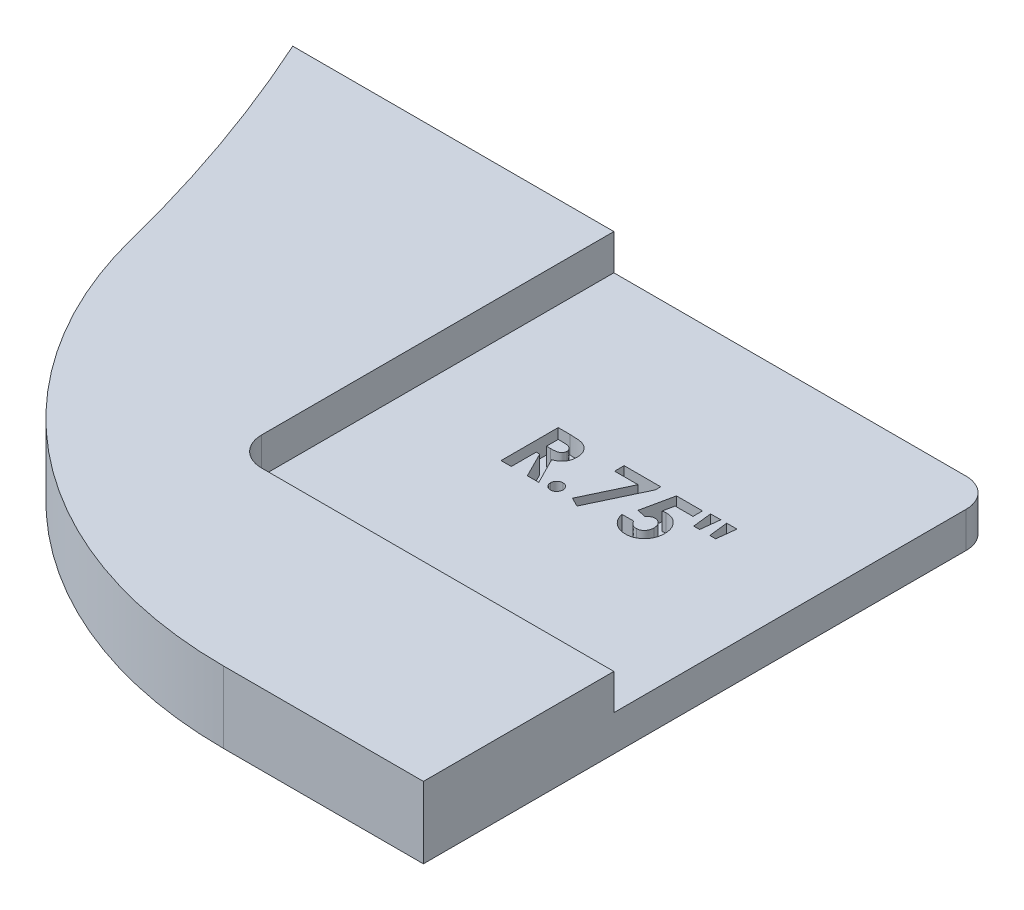
from build123d import *

# Parameters (mm, degrees)
BOSS_EXTRUDE1_DEPTH = 1.5875
FILLET1_R           = 19.05
SKETCH3_W           = 16.933333333
SKETCH3_H           = 16.933333333
CUT_EXTRUDE1_DEPTH  = 1.5875
CUT_EXTRUDE2_DEPTH  = 0.79375
FILLET2_R           = 1.27


with BuildPart() as part:
    # Sketch2 → Boss-Extrude1 (new, symmetric)
    with BuildSketch(Plane(origin=(0, 0, 0), x_dir=(1, 0, 0), z_dir=(0, 1, 0))):
        with BuildLine():
            Line((65.385731385, 1.5875), (90.785731385, 1.5875))
            Line((90.785731385, 1.5875), (90.785731385, 26.9875))
            Line((90.785731385, 26.9875), (59.577586966, 26.9875))
            ThreePointArc((59.577586966, 26.9875), (63.75929527, 14.579653345), (65.385731385, 1.5875))
        make_face()
    extrude(amount=BOSS_EXTRUDE1_DEPTH, both=True)

    # Fillet1
    fillet1_edges = [part.edges().sort_by_distance(p)[0] for p in [
        (65.385731385, 0, -1.5875),
    ]]
    fillet(fillet1_edges, radius=FILLET1_R)

    # Sketch3 → Cut-Extrude1 (cut)
    with BuildSketch(Plane(origin=(0, 1.5875, 0), x_dir=(1, 0, 0), z_dir=(0, 1, 0))):
        with Locations((82.319064719, 18.520833334)):
            Rectangle(SKETCH3_W, SKETCH3_H)
    extrude(amount=-CUT_EXTRUDE1_DEPTH, mode=Mode.SUBTRACT)

    # Sketch4 → Cut-Extrude2 (cut)
    with BuildSketch(Plane(origin=(0, 0, 0), x_dir=(1, 0, 0), z_dir=(0, 1, 0))):
        with BuildLine():
            Line((78.574192923, 19.790833333), (79.105394847, 19.790833333))
            add(Edge.make_bspline(
                [(79.105394847, 19.790833333), (79.140507132, 19.790708705), (79.208037947, 19.790469009), (79.305413695, 19.786687247), (79.39486671, 19.781424614), (79.476529437, 19.773393697), (79.550366938, 19.762745672), (79.616453216, 19.750193413), (79.67478634, 19.735887422), (79.725858268, 19.718061028), (79.771948157, 19.697953127), (79.814910342, 19.674848779), (79.855692632, 19.64900526), (79.894022441, 19.619742555), (79.930232865, 19.587587095), (79.964392216, 19.552506512), (79.996017791, 19.514203335), (80.024913764, 19.472919594), (80.051250117, 19.429490045), (80.07452593, 19.383855059), (80.093453859, 19.3359829), (80.110178714, 19.286565425), (80.122225085, 19.234896199), (80.13060316, 19.181478234), (80.136737259, 19.12612349), (80.13708994, 19.088517935), (80.137269847, 19.069334936)],
                knots=[0, 0, 0, 0, 1.749336639, 3.364467119, 4.854658419, 6.213483162, 7.451590619, 8.570285859, 9.5643256, 10.440900261, 11.26203566, 12.067320669, 12.869050712, 13.665104639, 14.467235401, 15.27997916, 16.102287765, 16.939272006, 17.78853747, 18.631303466, 19.488103222, 20.351255419, 21.228522269, 22.127379805, 23.044756219, 24, 24, 24, 24], degree=3))
            add(Edge.make_bspline(
                [(80.137269847, 19.069334936), (80.136802514, 19.049312291), (80.13588616, 19.010051534), (80.130950179, 18.952380684), (80.121928756, 18.897205248), (80.108264499, 18.844686774), (80.092559211, 18.794171608), (80.071675206, 18.746591786), (80.048105542, 18.701255329), (80.020112541, 18.658803538), (79.989391589, 18.618293474), (79.953663769, 18.581277228), (79.915243694, 18.545765316), (79.871971632, 18.513982085), (79.825755055, 18.483778467), (79.775675689, 18.456405945), (79.722060369, 18.431176438), (79.684366144, 18.417106723), (79.665090359, 18.409911859)],
                knots=[0, 0, 0, 0, 1.099860209, 2.156625411, 3.176576793, 4.16617041, 5.135385252, 6.078461593, 7.016046972, 7.938469504, 8.868247731, 9.803980173, 10.76021508, 11.73834243, 12.748633912, 13.790971185, 14.870363756, 16, 16, 16, 16], degree=3))
            Line((79.665090359, 18.409911859), (80.251244206, 17.250833333))
            Line((80.251244206, 17.250833333), (79.744465359, 17.250833333))
            Line((79.744465359, 17.250833333), (79.184769847, 18.358012821))
            Line((79.184769847, 18.358012821), (79.030090359, 18.358012821))
            Line((79.030090359, 18.358012821), (79.030090359, 17.250833333))
            Line((79.030090359, 17.250833333), (78.574192923, 17.250833333))
            Line((78.574192923, 17.250833333), (78.574192923, 19.790833333))
        make_face()
        with BuildLine():
            Line((79.030090359, 18.813910256), (79.207666481, 18.813910256))
            add(Edge.make_bspline(
                [(79.207666481, 18.813910256), (79.229376638, 18.814154771), (79.270946924, 18.814622963), (79.330730455, 18.816794634), (79.385028158, 18.822027288), (79.434073207, 18.82863855), (79.478112392, 18.836272207), (79.516752898, 18.847211702), (79.550590117, 18.858933647), (79.579223077, 18.873500984), (79.60368642, 18.890067205), (79.624808951, 18.908886845), (79.642280313, 18.930668181), (79.656660135, 18.954819292), (79.667846072, 18.981553787), (79.67601095, 19.010578183), (79.68057391, 19.042223104), (79.681098894, 19.064062409), (79.681372411, 19.075440705)],
                knots=[0, 0, 0, 0, 1.688639943, 3.233382647, 4.650958383, 5.928841754, 7.082724185, 8.122798841, 9.049171256, 9.863274652, 10.613301712, 11.341792392, 12.054588806, 12.776240173, 13.521029143, 14.301969904, 15.115324896, 16, 16, 16, 16], degree=3))
            add(Edge.make_bspline(
                [(79.681372411, 19.075440705), (79.680855301, 19.08890206), (79.679839536, 19.115344397), (79.669759991, 19.153412091), (79.653715532, 19.188646346), (79.631722973, 19.220887966), (79.604026204, 19.249153195), (79.572241976, 19.27406922), (79.53568431, 19.293770948), (79.501834662, 19.306765998), (79.471039394, 19.31454107), (79.443247637, 19.320334985), (79.411064614, 19.324441299), (79.37446603, 19.328796776), (79.333545176, 19.331621083), (79.288079008, 19.333682263), (79.238198105, 19.334525594), (79.203426378, 19.334795192), (79.185278661, 19.334935897)],
                knots=[0, 0, 0, 0, 1.020303359, 2.004196876, 2.966617323, 3.9489082, 4.950758222, 5.960522915, 7.003732012, 8.091992268, 8.70421221, 9.413913587, 10.24622431, 11.166358409, 12.212345909, 13.359657661, 14.621978493, 16, 16, 16, 16], degree=3))
            Line((79.185278661, 19.334935897), (79.030090359, 19.334935897))
            Line((79.030090359, 19.334935897), (79.030090359, 18.813910256))
        make_face(mode=Mode.SUBTRACT)
        with BuildLine():
            add(Edge.make_bspline(
                [(80.804833949, 17.771858974), (80.823237988, 17.770849925), (80.859472362, 17.768863281), (80.911826092, 17.754037168), (80.959075635, 17.727399942), (81.00132304, 17.692656297), (81.037046381, 17.650855054), (81.062866405, 17.603185847), (81.078945181, 17.551033843), (81.080720289, 17.514685471), (81.081628821, 17.496081731)],
                knots=[0, 0, 0, 0, 1.016957001, 2.002212695, 2.9757545, 3.99499976, 5.013036768, 5.994806404, 6.97370641, 8, 8, 8, 8], degree=3))
            add(Edge.make_bspline(
                [(81.081628821, 17.496081731), (81.080726241, 17.477475003), (81.078962761, 17.441120793), (81.062755141, 17.388867167), (81.037084965, 17.340806163), (81.001320174, 17.298556992), (80.959250596, 17.263158571), (80.911717457, 17.236766979), (80.859572095, 17.221099817), (80.823255542, 17.219221837), (80.804833949, 17.218269231)],
                knots=[0, 0, 0, 0, 1.023218912, 1.999186227, 2.986238111, 4.008388923, 5.030539734, 6.0011649, 6.986089706, 8, 8, 8, 8], degree=3))
            add(Edge.make_bspline(
                [(80.804833949, 17.218269231), (80.786407991, 17.219214091), (80.750082833, 17.2210768), (80.697856414, 17.236899038), (80.649972349, 17.26298237), (80.607892201, 17.29859993), (80.571967629, 17.340656555), (80.54702728, 17.389018808), (80.53066869, 17.441101093), (80.528929318, 17.477468333), (80.528039077, 17.496081731)],
                knots=[0, 0, 0, 0, 1.013427518, 1.99788335, 2.976245624, 3.997909735, 5.019573847, 6.001765691, 6.977268297, 8, 8, 8, 8], degree=3))
            add(Edge.make_bspline(
                [(80.528039077, 17.496081731), (80.528935192, 17.514692257), (80.530686038, 17.551053886), (80.546916333, 17.603032459), (80.5720076, 17.651005475), (80.607889205, 17.69261327), (80.650148211, 17.727574767), (80.69774717, 17.753906918), (80.750182516, 17.768886469), (80.786425524, 17.770857735), (80.804833949, 17.771858974)],
                knots=[0, 0, 0, 0, 1.025808215, 2.00424526, 2.981110158, 3.998665696, 5.017428914, 5.998734231, 6.983523959, 8, 8, 8, 8], degree=3))
        make_face()
        Polygon((81.504962154, 19.790833333), (83.133167282, 19.790833333), (83.133167282, 19.554234776), (82.012758629, 17.185705128), (81.609269045, 17.389230769), (82.54497818, 19.3675), (81.504962154, 19.3675), align=None)
        with BuildLine():
            Line((83.832786673, 19.790833333), (84.989321129, 19.790833333))
            Line((84.989321129, 19.790833333), (84.989321129, 19.3675))
            Line((84.989321129, 19.3675), (84.194044686, 19.3675))
            Line((84.194044686, 19.3675), (84.094825936, 18.887179487))
            add(Edge.make_bspline(
                [(84.094825936, 18.887179487), (84.108345911, 18.890944971), (84.13501008, 18.898371278), (84.175179683, 18.905818925), (84.214109626, 18.910646253), (84.239655217, 18.911290154), (84.252049494, 18.911602564)],
                knots=[0, 0, 0, 0, 1.05461699, 2.079921384, 3.068411212, 4, 4, 4, 4], degree=3))
            add(Edge.make_bspline(
                [(84.252049494, 18.911602564), (84.279057922, 18.910983682), (84.332297483, 18.909763728), (84.410180206, 18.898182388), (84.484757513, 18.879942129), (84.555801191, 18.853927756), (84.623241839, 18.820069377), (84.687161209, 18.779110231), (84.747637751, 18.730978377), (84.803597146, 18.675643681), (84.855014976, 18.614884932), (84.899719847, 18.549167915), (84.937900596, 18.479429693), (84.968268244, 18.405236773), (84.992236981, 18.327055137), (85.009557326, 18.244834683), (85.01979971, 18.158477969), (85.021180833, 18.099562957), (85.021885231, 18.069515224)],
                knots=[0, 0, 0, 0, 1.01440847, 1.999622559, 2.951875003, 3.895578053, 4.836219714, 5.782137149, 6.743708247, 7.735272588, 8.734977101, 9.730283169, 10.717124674, 11.717316708, 12.737475749, 13.78628267, 14.87096371, 16, 16, 16, 16], degree=3))
            add(Edge.make_bspline(
                [(85.021885231, 18.069515224), (85.021024446, 18.03912638), (85.019325864, 17.979160308), (85.008244177, 17.89098897), (84.988684799, 17.806540734), (84.961818037, 17.725589532), (84.926422798, 17.648730338), (84.883855179, 17.575166947), (84.833395476, 17.505445397), (84.775538871, 17.440280418), (84.712641153, 17.380718377), (84.645669931, 17.328321535), (84.575095697, 17.284230017), (84.500916749, 17.248596616), (84.423558676, 17.220404103), (84.342997997, 17.1998813), (84.2588432, 17.188112612), (84.201713026, 17.186516441), (84.172674494, 17.185705128)],
                knots=[0, 0, 0, 0, 1.06808661, 2.107647099, 3.116961351, 4.110378221, 5.100014249, 6.085620622, 7.093190682, 8.119403071, 9.144090782, 10.133780668, 11.103064255, 12.062861538, 13.020824475, 13.992378307, 14.979551724, 16, 16, 16, 16], degree=3))
            add(Edge.make_bspline(
                [(84.172674494, 17.185705128), (84.146706199, 17.186368833), (84.095491287, 17.187677798), (84.02005397, 17.195723384), (83.947324019, 17.209948055), (83.877687552, 17.230534838), (83.810411875, 17.255872468), (83.746274714, 17.287561963), (83.684923626, 17.324999911), (83.626532824, 17.36750307), (83.572051075, 17.415381231), (83.522325908, 17.467792126), (83.47705628, 17.524075143), (83.43721089, 17.584924643), (83.402914641, 17.650250725), (83.372500028, 17.719283505), (83.347605363, 17.792743905), (83.334972037, 17.843670736), (83.328551898, 17.869551282)],
                knots=[0, 0, 0, 0, 1.054957082, 2.080596141, 3.077793124, 4.061112343, 5.027190972, 5.994718051, 6.962465889, 7.943658696, 8.924948258, 9.904494768, 10.875059, 11.855380583, 12.854004648, 13.869083016, 14.917087635, 16, 16, 16, 16], degree=3))
            Line((83.328551898, 17.869551282), (83.849577539, 17.869551282))
            add(Edge.make_bspline(
                [(83.849577539, 17.869551282), (83.8591019, 17.851617118), (83.877611409, 17.816764116), (83.912820588, 17.770491519), (83.952235028, 17.731032236), (83.99549919, 17.698000741), (84.042893399, 17.673254108), (84.09248643, 17.654487406), (84.144901299, 17.643642824), (84.18059814, 17.642287144), (84.198624013, 17.641602564)],
                knots=[0, 0, 0, 0, 1.104910296, 2.147267069, 3.153527244, 4.136738762, 5.099945312, 6.05603338, 7.018353, 8, 8, 8, 8], degree=3))
            add(Edge.make_bspline(
                [(84.198624013, 17.641602564), (84.211187805, 17.642075272), (84.235907277, 17.643005333), (84.272327511, 17.647925589), (84.307092224, 17.657244443), (84.340459884, 17.670148889), (84.372520125, 17.686242191), (84.402813351, 17.706558936), (84.431866612, 17.729944262), (84.459237598, 17.756779004), (84.484027821, 17.786693499), (84.505766136, 17.818838663), (84.525203187, 17.852500223), (84.539600508, 17.8890116), (84.551390696, 17.927282549), (84.560073467, 17.96760176), (84.565262403, 18.010016324), (84.565742759, 18.038971558), (84.565987795, 18.053741987)],
                knots=[0, 0, 0, 0, 0.978869489, 1.925942215, 2.855067702, 3.774946051, 4.70828698, 5.642468714, 6.60995405, 7.609372294, 8.622401667, 9.629904756, 10.629323, 11.642352373, 12.678539694, 13.745912462, 14.850161547, 16, 16, 16, 16], degree=3))
            add(Edge.make_bspline(
                [(84.565987795, 18.053741987), (84.565703403, 18.068169561), (84.565149826, 18.096253185), (84.560570526, 18.137490004), (84.552378247, 18.176616282), (84.541216196, 18.213931698), (84.526927439, 18.249209654), (84.509465622, 18.282660141), (84.488756147, 18.31411408), (84.46468783, 18.3429311), (84.439021624, 18.369362889), (84.411447871, 18.392479922), (84.382214997, 18.411665454), (84.352231377, 18.428414982), (84.320300172, 18.440604923), (84.287139388, 18.448999686), (84.252783897, 18.455159425), (84.229350762, 18.455521332), (84.217450135, 18.455705128)],
                knots=[0, 0, 0, 0, 1.166249705, 2.270133367, 3.348514167, 4.393962215, 5.415026464, 6.420877785, 7.440098956, 8.453121383, 9.451844239, 10.415694839, 11.355045125, 12.27538808, 13.187007209, 14.108269027, 15.039275622, 16, 16, 16, 16], degree=3))
            add(Edge.make_bspline(
                [(84.217450135, 18.455705128), (84.204523289, 18.455214626), (84.178615115, 18.454231555), (84.140122054, 18.446232567), (84.102093112, 18.433287203), (84.064316809, 18.415427023), (84.027168141, 18.392053682), (83.989666735, 18.364639432), (83.953067845, 18.33119237), (83.929797253, 18.306280922), (83.917758629, 18.293393429)],
                knots=[0, 0, 0, 0, 0.88288272, 1.769486374, 2.674910571, 3.623812639, 4.617874466, 5.670434592, 6.794841017, 8, 8, 8, 8], degree=3))
            Line((83.917758629, 18.293393429), (83.534112795, 18.381418269))
            Line((83.534112795, 18.381418269), (83.832786673, 19.790833333))
        make_face()
        Polygon((86.357013436, 19.009294872), (86.096500616, 19.009294872), (85.998808308, 19.855961538), (86.454705744, 19.855961538), align=None)
        Polygon((85.64060318, 19.009294872), (85.380090359, 19.009294872), (85.282398052, 19.855961538), (85.738295488, 19.855961538), align=None)
    extrude(amount=-CUT_EXTRUDE2_DEPTH, mode=Mode.SUBTRACT)

    # Fillet2
    fillet2_edges = [part.edges().sort_by_distance(p)[0] for p in [
        (90.785731385, -0.79375, -26.9875),
        (73.852398052, 0.79375, -10.054166667),
    ]]
    fillet(fillet2_edges, radius=FILLET2_R)


solid = part.part
